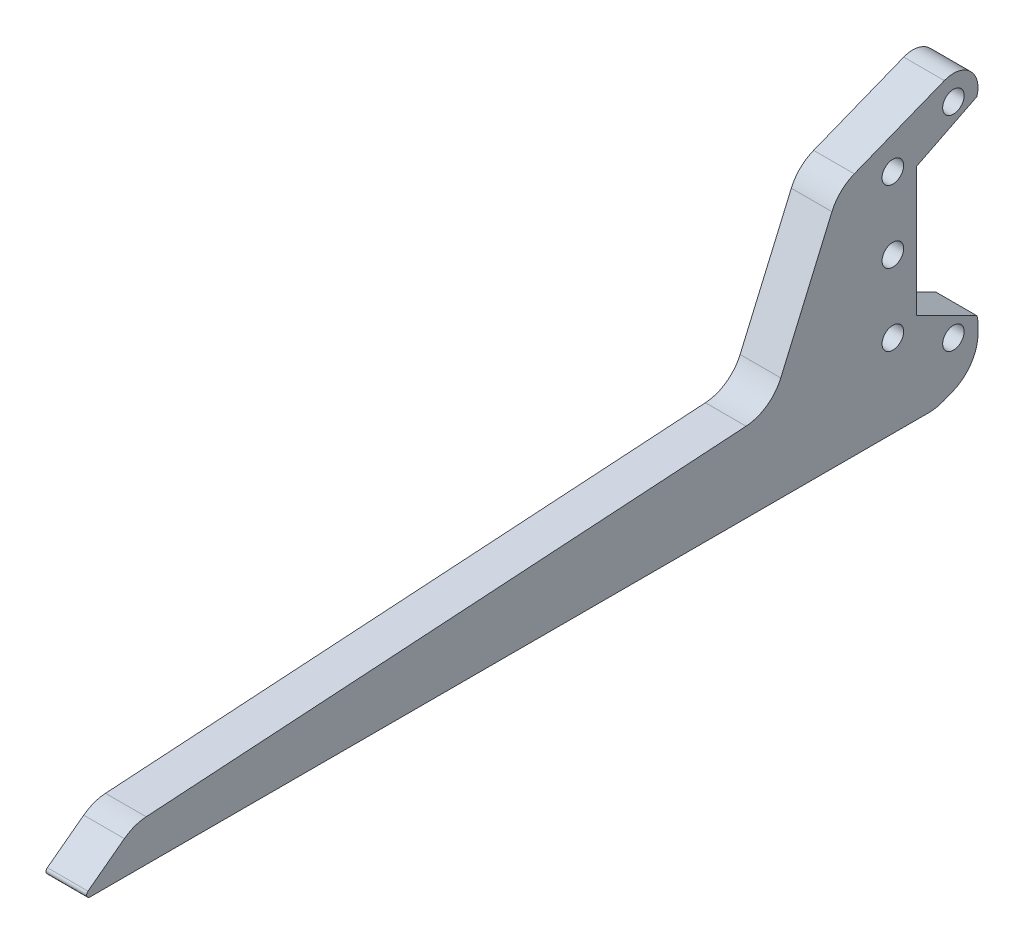
from build123d import *

# Parameters (mm, degrees)
SKETCH1_R               = 7.9375
SKETCH1_R_2             = 11.1125
BOSS_EXTRUDE1_DEPTH     = 12.7
F_8_CLEARANCE_HOLE1_D   = 4.4958
SKETCH5_R               = 18.415
CUT_EXTRUDE1_DEPTH      = 13.7
SKETCH7_R               = 9.525
CUT_EXTRUDE2_DEPTH      = 13.7
CUT_EXTRUDE3_DEPTH      = 13.7
BOSS_EXTRUDE2_DEPTH     = 12.7
CUT_EXTRUDE4_DEPTH      = 13.7
SKETCH11_W              = 12.7
SKETCH11_H              = 178.054
CUT_EXTRUDE5_DEPTH      = 3.175
BOSS_EXTRUDE3_DEPTH     = 19.05
CUT_EXTRUDE6_DEPTH      = 20.05
F_3_8_CLEARANCE_HOLE1_D = 10.0838
CUT_EXTRUDE7_DEPTH      = 20.05
BOSS_EXTRUDE4_DEPTH     = 19.05
FILLET1_R               = 19.05
FILLET3_R               = 1.5875


with BuildPart() as part:
    # Sketch1 → Boss-Extrude1 (new body)
    with BuildSketch(Plane(origin=(0, 0, 0), x_dir=(0, 0, -1), z_dir=(1, 0, 0))):
        with BuildLine():
            Line((93.345, 0), (55.245, 50.8))
            Line((55.245, 50.8), (-160.655, 50.8))
            ThreePointArc((-160.655, 50.8), (-211.455, 0), (-160.655, -50.8))
            Line((-160.655, -50.8), (55.245, -50.8))
            Line((55.245, -50.8), (93.345, 0))
        make_face()
        with Locations((-88.9, 0)):
            Circle(SKETCH1_R, mode=Mode.SUBTRACT)
        with Locations((-38.1, 0)):
            Circle(SKETCH1_R, mode=Mode.SUBTRACT)
        with Locations((-160.655, 0)):
            Circle(SKETCH1_R_2, mode=Mode.SUBTRACT)
        Circle(SKETCH1_R, mode=Mode.SUBTRACT)
    extrude(amount=BOSS_EXTRUDE1_DEPTH)

    # #8 Clearance Hole1 (through all)
    with Locations(Plane.ZY):
        with Locations((-17.691104559, 17.691104559), (17.691104559, 17.691104559), (17.691104559, -17.691104559), (-17.691104559, -17.691104559)):
            Hole(F_8_CLEARANCE_HOLE1_D / 2)

    # Sketch5 → Cut-Extrude1 (cut, through all)
    with BuildSketch(Plane.ZY):
        Circle(SKETCH5_R)
    extrude(amount=-CUT_EXTRUDE1_DEPTH, mode=Mode.SUBTRACT)

    # Sketch7 → Cut-Extrude2 (cut, through all)
    with BuildSketch(Plane.ZY):
        with Locations((-55.245, 0)):
            Circle(SKETCH7_R)
    extrude(amount=-CUT_EXTRUDE2_DEPTH, mode=Mode.SUBTRACT)

    # Sketch8 → Cut-Extrude3 (cut, through all)
    with BuildSketch(Plane(origin=(12.7, 0, 0), x_dir=(0, 0, -1), z_dir=(1, 0, 0))):
        Polygon((-160.655, 50.8), (-211.455, 25.4), (-211.455, -25.4), (-160.655, -50.8), (-233.239745749, -50.8), (-233.239745749, 50.8), align=None)
    extrude(amount=-CUT_EXTRUDE3_DEPTH, mode=Mode.SUBTRACT)

    # Sketch9 → Boss-Extrude2 (add)
    with BuildSketch(Plane(origin=(12.7, 0, 0), x_dir=(0, 0, -1), z_dir=(1, 0, 0))):
        Polygon((-160.655, 50.8), (-211.455, 25.4), (-211.455, 0), (-211.455, -25.4), (-160.655, -50.8), (-160.655, -40.64), (-202.749323348, 0), (-160.655, 40.64), align=None)
    extrude(amount=-BOSS_EXTRUDE2_DEPTH)

    # Sketch10 → Cut-Extrude4 (cut, through all)
    with BuildSketch(Plane.ZY):
        Polygon((-79.0575, -19.05), (-79.0575, 19.05), (-93.345, 0), align=None)
    extrude(amount=-CUT_EXTRUDE4_DEPTH, mode=Mode.SUBTRACT)

    # Sketch11 → Cut-Extrude5 (cut)
    with BuildSketch(Plane(origin=(0, 50.8, 0), x_dir=(1, 0, 0), z_dir=(0, 1, 0))):
        with Locations((6.35, -52.705)):
            Rectangle(SKETCH11_W, SKETCH11_H)
    cut_extrude5 = extrude(amount=-CUT_EXTRUDE5_DEPTH, mode=Mode.SUBTRACT)

    # Mirror1: Cut-Extrude5 across plane
    add(cut_extrude5.mirror(Plane.ZX), mode=Mode.SUBTRACT)

    # Sketch13 → Cut-Extrude6 (cut, through all)
    with BuildSketch(Plane(origin=(12.7, 0, 0), x_dir=(0, 0, -1), z_dir=(1, 0, 0))):
        Polygon((-161.254612663, -53.34), (-139.192, -53.34), (-139.192, -50.165), (33.782, -50.165), (33.782, -53.34), (56.515, -53.34), (81.5975, -19.896666667), (81.5975, 19.896666667), (56.515, 53.34), (33.782, 53.34), (33.782, 50.165), (-139.192, 50.165), (-139.192, 53.34), (-161.254612663, 53.34), (-213.995, 26.969806331), (-213.995, -26.969806331), align=None)
    extrude(amount=-CUT_EXTRUDE6_DEPTH, mode=Mode.SUBTRACT)


with BuildPart() as body_2:
    # Sketch12 → Boss-Extrude3 (new body)
    with BuildSketch(Plane(origin=(12.7, 0, 0), x_dir=(0, 0, -1), z_dir=(1, 0, 0))):
        with BuildLine():
            ThreePointArc((-211.89681554, -56.397839854), (-236.855, 0), (-211.89681554, 56.397839854))
            Line((-211.89681554, 56.397839854), (-243.205, 43.989212666))
            Line((-243.205, 43.989212666), (-243.205, -43.989212666))
            Line((-243.205, -43.989212666), (-211.89681554, -56.397839854))
        make_face()
        with BuildLine():
            Line((-217.805, 29.324515829), (-162.154031657, 57.15))
            Line((-162.154031657, 57.15), (-166.916531657, 66.675))
            Line((-166.916531657, 66.675), (-185.966531657, 66.675))
            Line((-185.966531657, 66.675), (-211.89681554, 56.397839854))
            ThreePointArc((-211.89681554, 56.397839854), (-236.855, 0), (-211.89681554, -56.397839854))
            Line((-211.89681554, -56.397839854), (-185.966531657, -66.675))
            Line((-185.966531657, -66.675), (-166.916531657, -66.675))
            Line((-166.916531657, -66.675), (-162.154031657, -57.15))
            Line((-162.154031657, -57.15), (-217.805, -29.324515829))
            Line((-217.805, -29.324515829), (-217.805, 29.324515829))
        make_face()
    extrude(amount=-BOSS_EXTRUDE3_DEPTH)

    # 3/8 Clearance Hole1 (through all)
    with Locations(Plane(origin=(12.7, 0, 0), x_dir=(0, 0, -1), z_dir=(1, 0, 0))):
        with Locations((-230.505, 0), (-230.505, 33.690140829), (-202.106936686, 47.889172486), (-230.505, -33.690140829), (-202.106936686, -47.889172486)):
            Hole(F_3_8_CLEARANCE_HOLE1_D / 2)

    # Sketch16 → Cut-Extrude7 (cut, through all)
    with BuildSketch(Plane(origin=(12.7, 0, 0), x_dir=(0, 0, -1), z_dir=(1, 0, 0))):
        with BuildLine():
            ThreePointArc((-190.589767426, 47.889172486), (-190.722432786, 46.146112328), (-191.117372542, 44.443208515))
            Line((-191.117372542, 44.443208515), (-162.86398324, 58.569903166))
            Line((-162.86398324, 58.569903166), (-166.916531657, 66.675))
            Line((-166.916531657, 66.675), (-185.966531657, 66.675))
            Line((-185.966531657, 66.675), (-206.35048523, 58.596062021))
            ThreePointArc((-206.35048523, 58.596062021), (-195.635015761, 57.415946719), (-190.589767426, 47.889172486))
        make_face()
        with BuildLine():
            Line((-162.86398324, 58.569903166), (-191.117372542, 44.443208515))
            ThreePointArc((-191.117372542, 44.443208515), (-191.551739911, 43.281243579), (-192.108559765, 42.172735946))
            Line((-192.108559765, 42.172735946), (-162.154031657, 57.15))
            Line((-162.154031657, 57.15), (-162.86398324, 58.569903166))
        make_face()
        with BuildLine():
            Line((-191.117372542, 44.443208515), (-205.943903995, 37.029942788))
            ThreePointArc((-205.943903995, 37.029942788), (-204.753711625, 36.680257722), (-203.532813606, 36.460609025))
            Line((-203.532813606, 36.460609025), (-192.108559765, 42.172735946))
            ThreePointArc((-192.108559765, 42.172735946), (-191.551739911, 43.281243579), (-191.117372542, 44.443208515))
        make_face()
        with BuildLine():
            Line((-219.3925, 30.305644786), (-219.3925, -30.305644786))
            Line((-219.3925, -30.305644786), (-205.943903995, -37.029942788))
            ThreePointArc((-205.943903995, -37.029942788), (-204.753711625, -36.680257722), (-203.532813606, -36.460609025))
            Line((-203.532813606, -36.460609025), (-217.805, -29.324515829))
            Line((-217.805, -29.324515829), (-217.805, 29.324515829))
            Line((-217.805, 29.324515829), (-203.532813606, 36.460609025))
            ThreePointArc((-203.532813606, 36.460609025), (-204.753711625, 36.680257722), (-205.943903995, 37.029942788))
            Line((-205.943903995, 37.029942788), (-219.3925, 30.305644786))
        make_face()
        with BuildLine():
            ThreePointArc((-203.532813606, -36.460609025), (-204.753711625, -36.680257722), (-205.943903995, -37.029942788))
            Line((-205.943903995, -37.029942788), (-191.117372542, -44.443208515))
            ThreePointArc((-191.117372542, -44.443208515), (-191.551739911, -43.281243579), (-192.108559765, -42.172735946))
            Line((-192.108559765, -42.172735946), (-203.532813606, -36.460609025))
        make_face()
        with BuildLine():
            ThreePointArc((-192.108559765, -42.172735946), (-191.551739911, -43.281243579), (-191.117372542, -44.443208515))
            Line((-191.117372542, -44.443208515), (-162.86398324, -58.569903166))
            Line((-162.86398324, -58.569903166), (-162.154031657, -57.15))
            Line((-162.154031657, -57.15), (-192.108559765, -42.172735946))
        make_face()
        with BuildLine():
            Line((-162.86398324, -58.569903166), (-191.117372542, -44.443208515))
            ThreePointArc((-191.117372542, -44.443208515), (-190.722432786, -46.146112328), (-190.589767426, -47.889172486))
            Line((-190.589767426, -47.889172486), (-190.589767426, -64.842635395))
            Line((-190.589767426, -64.842635395), (-185.966531657, -66.675))
            Line((-185.966531657, -66.675), (-166.916531657, -66.675))
            Line((-166.916531657, -66.675), (-162.86398324, -58.569903166))
        make_face()
    extrude(amount=-CUT_EXTRUDE7_DEPTH, mode=Mode.SUBTRACT)

    # Sketch17 → Boss-Extrude4 (add)
    with BuildSketch(Plane(origin=(12.7, 0, 0), x_dir=(0, 0, -1), z_dir=(1, 0, 0))):
        Polygon((-490.855, -72.564212666), (-210.072064852, -72.564212666), (-190.589767426, -64.842635395), (-243.205, -43.989212666), (-243.205, 43.989212666), (-255.905, 38.955718453), (-287.655, -34.464212666), (-586.105, -53.514212666), (-611.505, -72.564212666), (-497.205, -72.564212666), align=None)
    extrude(amount=-BOSS_EXTRUDE4_DEPTH)

    # Fillet1
    fillet1_edges = [body_2.edges().sort_by_distance(p)[0] for p in [
        (3.175, -72.564212666, 210.072064852),
        (3.175, -53.514212666, 586.105),
        (3.175, -34.464212666, 287.655),
        (3.175, 38.955718453, 255.905),
        (3.175, -64.842635395, 190.589767426),
    ]]
    fillet(fillet1_edges, radius=FILLET1_R)

    # Fillet3
    fillet3_edges = [body_2.edges().sort_by_distance(p)[0] for p in [
        (3.175, -72.564212666, 611.505),
    ]]
    fillet(fillet3_edges, radius=FILLET3_R)


solid = body_2.part
